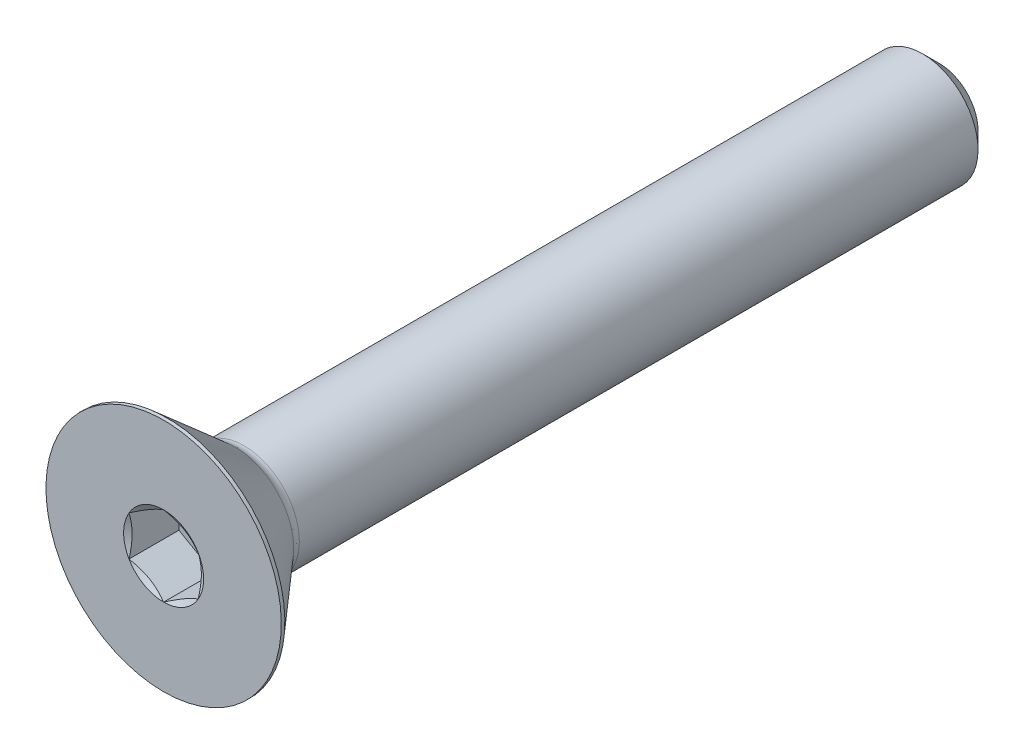
from build123d import *

# Parameters (mm, degrees)
SKETCH1_W           = 44.45
SKETCH1_H           = 3.175
CHAMFER1_SIZE       = 0.9525
CUT_EXTRUDE2_DEPTH  = 2.86258
BOSS_EXTRUDE2_START = -17.623191003
SKETCH9_R           = 3.175
BOSS_EXTRUDE2_DEPTH = 17.623191003


with BuildPart() as part:
    # Sketch1 → Revolve1 (revolve)
    with BuildSketch(Plane(origin=(0, 0, 0), x_dir=(0, 0, -1), z_dir=(1, 0, 0))):
        with Locations((22.225, 1.5875)):
            Rectangle(SKETCH1_W, SKETCH1_H)
    revolve(axis=Axis((0, 0, -44.45), (0, 0, 1)))

    # Chamfer1
    chamfer1_edges = [part.edges().sort_by_distance(p)[0] for p in [
        (0, -3.175, -44.45),
    ]]
    chamfer(chamfer1_edges, length=CHAMFER1_SIZE)

    # Sketch7 → Revolve2 (revolve)
    with BuildSketch(Plane(origin=(0, 0, 0), x_dir=(0, 0, -1), z_dir=(1, 0, 0)), mode=Mode.PRIVATE) as revolve2_sk:
        with BuildLine():
            Line((0, 6.7437), (0.20447, 6.7437))
            Line((0.20447, 6.7437), (4.0894, 3.366581874))
            ThreePointArc((4.0894, 3.366581874), (4.328282675, 3.224461616), (4.601808997, 3.175))
            Line((4.601808997, 3.175), (4.601808997, 0))
            Line((4.601808997, 0), (0, 0))
            Line((0, 0), (0, 6.7437))
        make_face()
    revolve(revolve2_sk.sketch.rotate(Axis((0, 0, 0), (0, 0, -1)), 180), axis=Axis((0, 0, 0), (0, 0, -1)))

    # Boss-Extrude1 cone 1 section (through the dimple's axis) → Boss-Extrude1 (revolve)
    with BuildSketch(Plane(origin=(0, 0, -4.601808997), x_dir=(0, -1, 0), z_dir=(1, 0, 0))):
        Polygon((0, 0), (3.175, 0), (0, 3.06606186), align=None)
    revolve(axis=Axis((0, 0, -4.601808997), (0, 0, -1)))

    # Sketch5 → Cut-Extrude2 (cut)
    with BuildSketch(Plane.XY):
        Polygon((0, 2.291358881), (-1.984375, 1.14567944), (-1.984375, -1.14567944), (0, -2.291358881), (1.984375, -1.14567944), (1.984375, 1.14567944), align=None)
    extrude(amount=-CUT_EXTRUDE2_DEPTH, mode=Mode.SUBTRACT)

    # Cut-Extrude3 cone 1 section (through the dimple's axis) → Cut-Extrude3 (revolve, cut)
    with BuildSketch(Plane(origin=(0, 0, 0), x_dir=(0, -1, 0), z_dir=(1, 0, 0))):
        Polygon((0, 0), (2.291358881, 0), (0, 1.322916667), align=None)
    revolve(axis=Axis((0, 0, 0), (0, 0, -1)), mode=Mode.SUBTRACT)

    # Sketch9 → Boss-Extrude2 (add)
    with BuildSketch(Plane.XY.offset(-4.601808997).offset(BOSS_EXTRUDE2_START)):
        with Locations(Location((0, 0, 0), (0, 0, 90))):
            Circle(SKETCH9_R)
    extrude(amount=BOSS_EXTRUDE2_DEPTH)


solid = part.part
